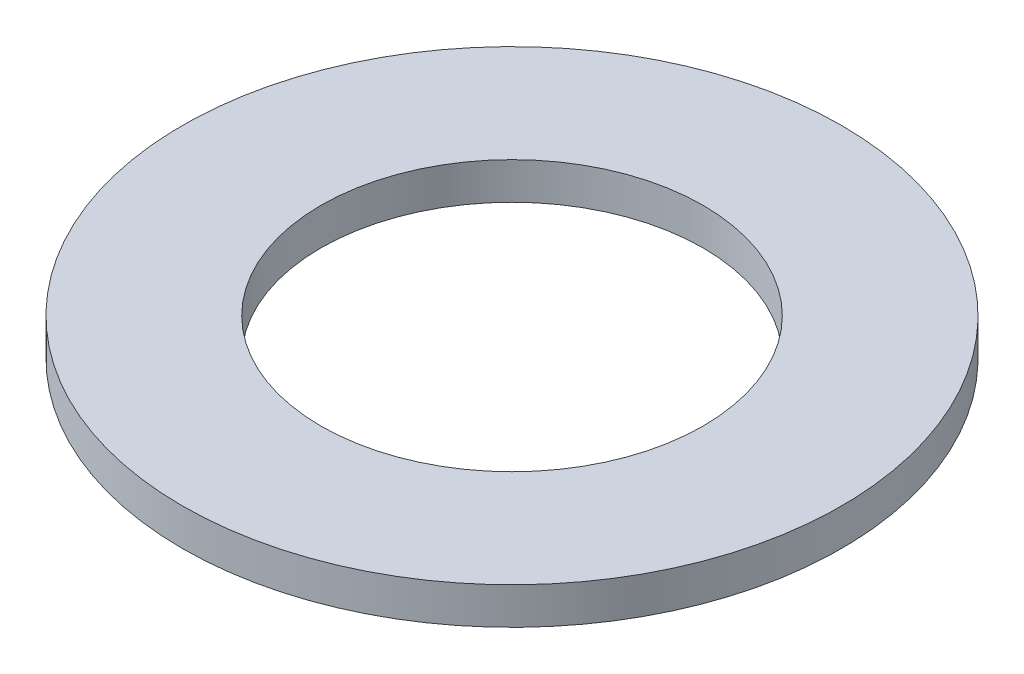
from build123d import *

# Parameters (mm, degrees)
SKETCH1_R           = 22.225
BOSS_EXTRUDE1_DEPTH = 2.4892
SKETCH5_R           = 12.8905
CUT_EXTRUDE1_DEPTH  = 3.4892


with BuildPart() as part:
    # Sketch1 → Boss-Extrude1 (new body)
    with BuildSketch(Plane(origin=(0, 0, 0), x_dir=(1, 0, 0), z_dir=(0, 1, 0))):
        Circle(SKETCH1_R)
    extrude(amount=BOSS_EXTRUDE1_DEPTH)

    # Sketch5 → Cut-Extrude1 (cut, through all)
    with BuildSketch(Plane(origin=(0, 2.4892, 0), x_dir=(-1, 0, 0), z_dir=(0, 1, 0))):
        Circle(SKETCH5_R)
    extrude(amount=-CUT_EXTRUDE1_DEPTH, mode=Mode.SUBTRACT)


solid = part.part
